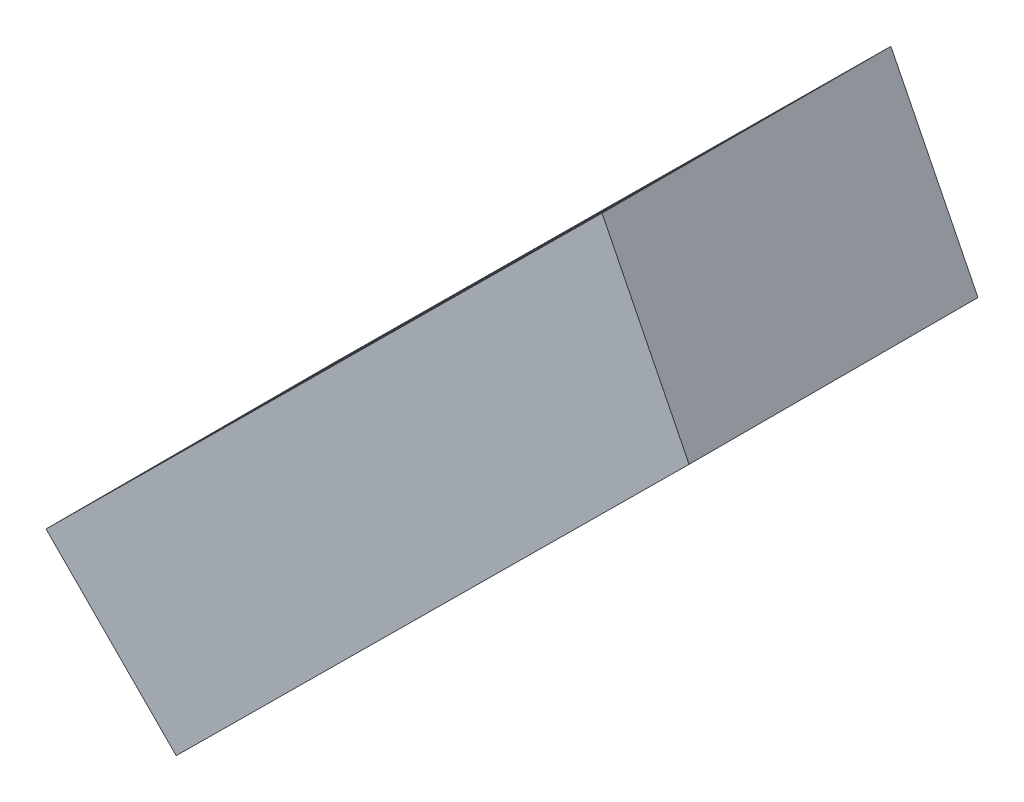
from build123d import *

# Parameters (mm, degrees)
BOSS_EXTRUDE1_DEPTH = 0.5


with BuildPart() as part:
    # Sketch1 → Boss-Extrude1 (new body)
    with BuildSketch(Plane(origin=(0, 0, -0.375), x_dir=(-1, 0, 0), z_dir=(0, 0, -1))):
        Polygon((1.832075314, 1.188843061), (1.681304445, 0.887671177), (2.56905624, 0.007083233), (2.794411885, 0.234272214), align=None)
    extrude(amount=-BOSS_EXTRUDE1_DEPTH)


solid = part.part
